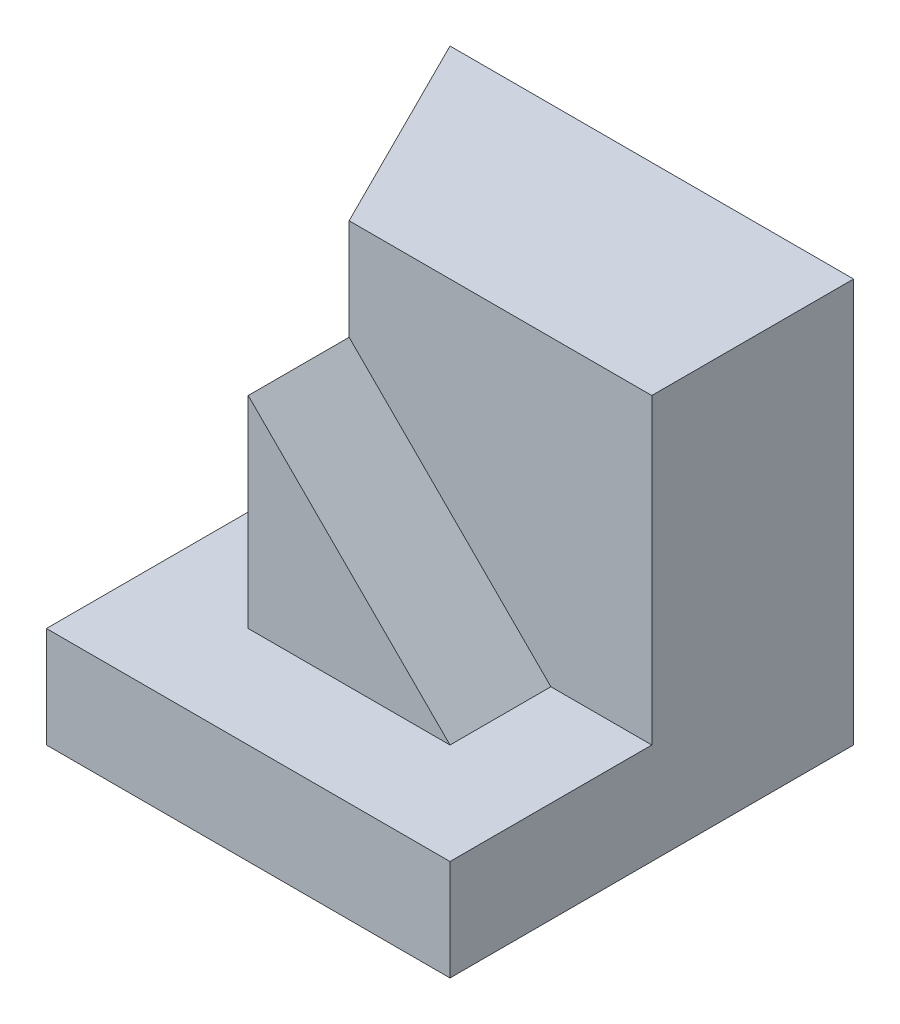
from build123d import *

# Parameters (mm, degrees)
SKETCH1_W           = 40
SKETCH1_H           = 40
BOSS_EXTRUDE1_DEPTH = 40
SKETCH2_W           = 10
SKETCH2_H           = 10
CUT_EXTRUDE1_DEPTH  = 40
SKETCH3_W           = 10
SKETCH3_H           = 10
CUT_EXTRUDE2_DEPTH  = 20
SKETCH5_W           = 10
SKETCH5_H           = 10
CUT_EXTRUDE3_DEPTH  = 20
CUT_EXTRUDE5_DEPTH  = 30
CUT_EXTRUDE6_DEPTH  = 10


with BuildPart() as part:
    # Sketch1 → Boss-Extrude1 (new body)
    with BuildSketch(Plane.XY):
        with Locations((20, 20)):
            Rectangle(SKETCH1_W, SKETCH1_H)
    extrude(amount=BOSS_EXTRUDE1_DEPTH)

    # Sketch2 → Cut-Extrude1 (cut)
    with BuildSketch(Plane.ZY):
        with Locations((25, 35)):
            Rectangle(SKETCH2_W, SKETCH2_H)
        Polygon((40, 10), (40, 40), (30, 40), (30, 30), (30, 10), align=None)
    extrude(amount=-CUT_EXTRUDE1_DEPTH, mode=Mode.SUBTRACT)

    # Sketch3 → Cut-Extrude2 (cut)
    with BuildSketch(Plane(origin=(0, 30, 0), x_dir=(1, 0, 0), z_dir=(0, 1, 0))):
        with Locations((35, -25)):
            Rectangle(SKETCH3_W, SKETCH3_H)
    extrude(amount=-CUT_EXTRUDE2_DEPTH, mode=Mode.SUBTRACT)

    # Sketch5 → Cut-Extrude3 (cut)
    with BuildSketch(Plane(origin=(0, 30, 0), x_dir=(1, 0, 0), z_dir=(0, 1, 0))):
        with Locations((5, -25)):
            Rectangle(SKETCH5_W, SKETCH5_H)
    extrude(amount=-CUT_EXTRUDE3_DEPTH, mode=Mode.SUBTRACT)

    # Sketch6 → Cut-Extrude5 (cut)
    with BuildSketch(Plane(origin=(0, 40, 0), x_dir=(1, 0, 0), z_dir=(0, 1, 0))):
        Polygon((10, -20), (0, 0), (0, -20), align=None)
    extrude(amount=-CUT_EXTRUDE5_DEPTH, mode=Mode.SUBTRACT)

    # Sketch7 → Cut-Extrude6 (cut)
    with BuildSketch(Plane.XY.offset(30)):
        Polygon((10, 30), (30, 10), (30, 30), align=None)
    extrude(amount=-CUT_EXTRUDE6_DEPTH, mode=Mode.SUBTRACT)


solid = part.part
